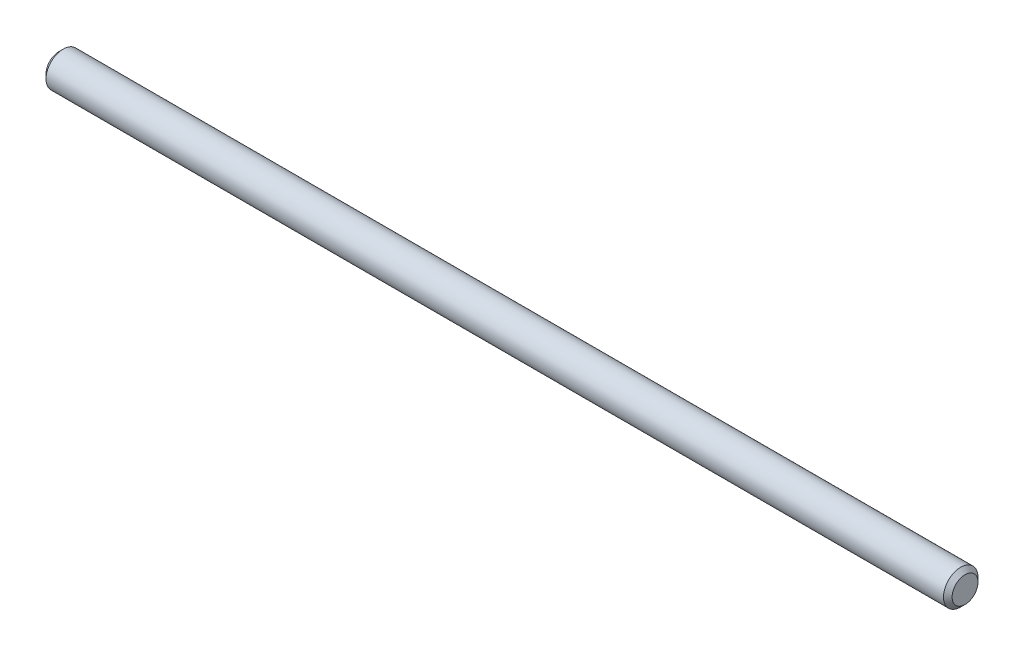
from build123d import *

# Parameters (mm, degrees)
SKETCH1_R           = 2
BOSS_EXTRUDE1_DEPTH = 52.5
CHAMFER1_SIZE       = 0.5


with BuildPart() as part:
    # Sketch1 → Boss-Extrude1 (new body, symmetric)
    with BuildSketch(Plane(origin=(0, 0, 0), x_dir=(0, 0, -1), z_dir=(1, 0, 0))):
        Circle(SKETCH1_R)
    extrude(amount=BOSS_EXTRUDE1_DEPTH, both=True)

    # Chamfer1
    chamfer1_edges = [part.edges().sort_by_distance(p)[0] for p in [
        (-52.5, 0, 2),
        (52.5, 0, 2),
    ]]
    chamfer(chamfer1_edges, length=CHAMFER1_SIZE)


solid = part.part
